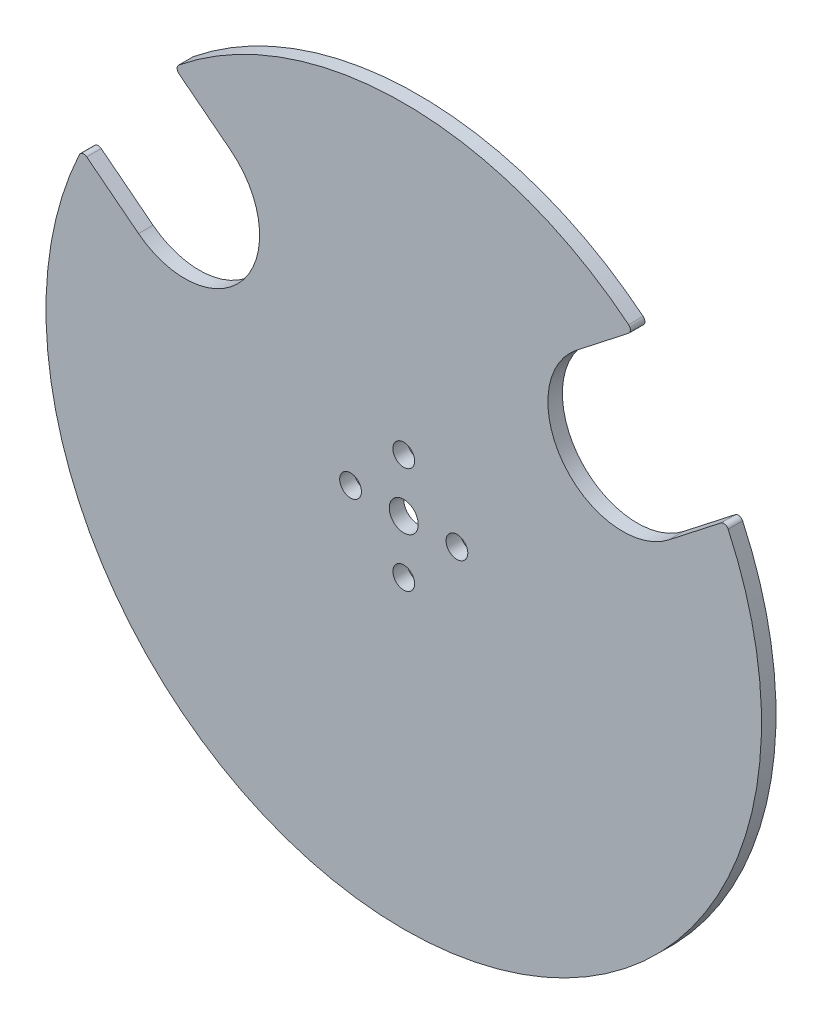
from build123d import *

# Parameters (mm, degrees)
ESQUISSE1_R        = 2.25
ESQUISSE1_R_2      = 3
BOSS_EXTRU_1_DEPTH = 3
CONG_3_R           = 1


with BuildPart() as part:
    # Esquisse1 → Boss.-Extru.1 (new body)
    with BuildSketch(Plane.XY):
        with BuildLine():
            Line((66.562015248, 32.334163451), (54.8533712, 23.18636815))
            ThreePointArc((54.8533712, 23.18636815), (33.096451651, 25.857781964), (35.767865465, 47.614701512))
            Line((35.767865465, 47.614701512), (47.476509513, 56.762496813))
            ThreePointArc((47.476509513, 56.762496813), (0, 74), (-47.476509513, 56.762496813))
            Line((-47.476509513, 56.762496813), (-35.767865465, 47.614701512))
            ThreePointArc((-35.767865465, 47.614701512), (-33.096451651, 25.857781964), (-54.8533712, 23.18636815))
            Line((-54.8533712, 23.18636815), (-66.562015248, 32.334163451))
            ThreePointArc((-66.562015248, 32.334163451), (0, -74), (66.562015248, 32.334163451))
        make_face()
        with Locations((0, 11)):
            Circle(ESQUISSE1_R, mode=Mode.SUBTRACT)
        with Locations((11, 0)):
            Circle(ESQUISSE1_R, mode=Mode.SUBTRACT)
        with Locations((0, -11)):
            Circle(ESQUISSE1_R, mode=Mode.SUBTRACT)
        with Locations((-11, 0)):
            Circle(ESQUISSE1_R, mode=Mode.SUBTRACT)
        Circle(ESQUISSE1_R_2, mode=Mode.SUBTRACT)
    extrude(amount=BOSS_EXTRU_1_DEPTH)

    # Congé3
    cong_3_edges = [part.edges().sort_by_distance(p)[0] for p in [
        (-66.562015248, 32.334163451, 1.5),
        (-47.476509513, 56.762496813, 1.5),
        (47.476509513, 56.762496813, 1.5),
        (66.562015248, 32.334163451, 1.5),
    ]]
    fillet(cong_3_edges, radius=CONG_3_R)


solid = part.part
